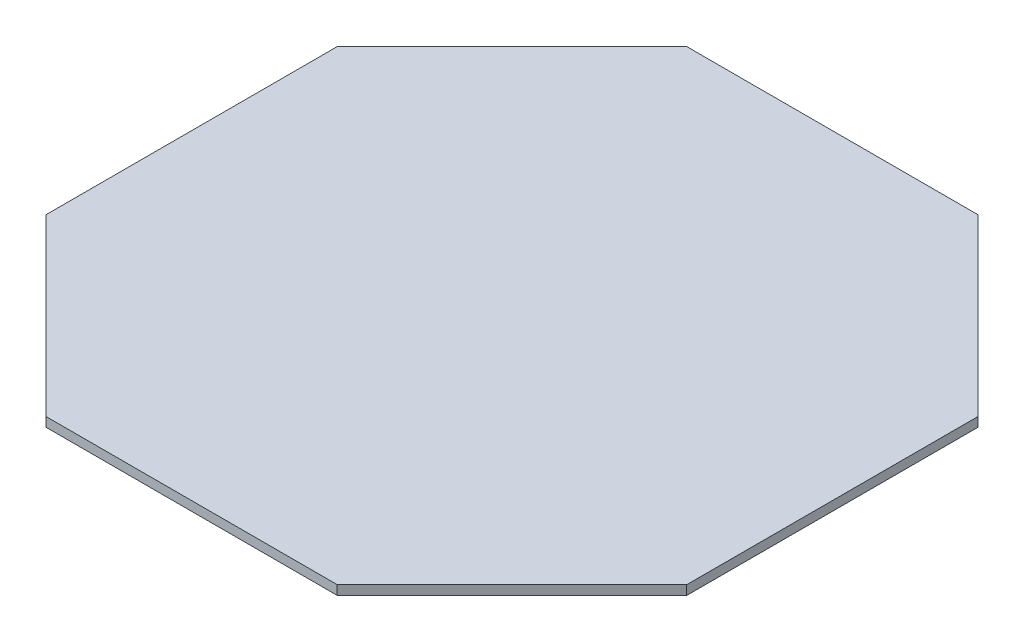
from build123d import *

# Parameters (mm, degrees)
BOSS_EXTRUDE1_DEPTH = 0.8


with BuildPart() as part:
    # Sketch1 → Boss-Extrude1 (new body, symmetric)
    with BuildSketch(Plane(origin=(0, 0, 0), x_dir=(1, 0, 0), z_dir=(0, 1, 0))):
        Polygon((-55, 25), (-55, -25), (-25, -55), (25, -55), (55, -25), (55, 25), (25, 55), (-25, 55), align=None)
    extrude(amount=BOSS_EXTRUDE1_DEPTH, both=True)


solid = part.part
